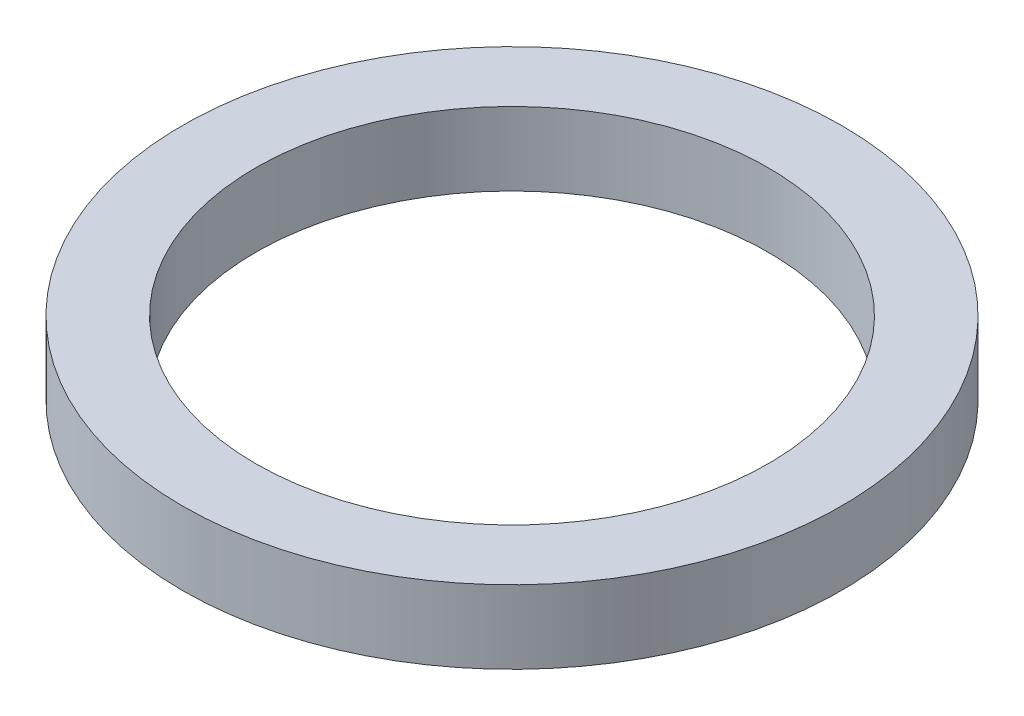
from build123d import *

# Parameters (mm, degrees)
SKETCH2_R           = 9
BOSS_EXTRUDE1_DEPTH = 2
SKETCH4_R           = 7
CUT_EXTRUDE3_DEPTH  = 2


with BuildPart() as part:
    # Sketch2 → Boss-Extrude1 (new body)
    with BuildSketch(Plane(origin=(0, 0, 0), x_dir=(1, 0, 0), z_dir=(0, 1, 0))):
        Circle(SKETCH2_R)
    extrude(amount=BOSS_EXTRUDE1_DEPTH)

    # Sketch4 → Cut-Extrude3 (cut)
    with BuildSketch(Plane(origin=(0, 2, 0), x_dir=(1, 0, 0), z_dir=(0, 1, 0))):
        Circle(SKETCH4_R)
    extrude(amount=-CUT_EXTRUDE3_DEPTH, mode=Mode.SUBTRACT)


solid = part.part
